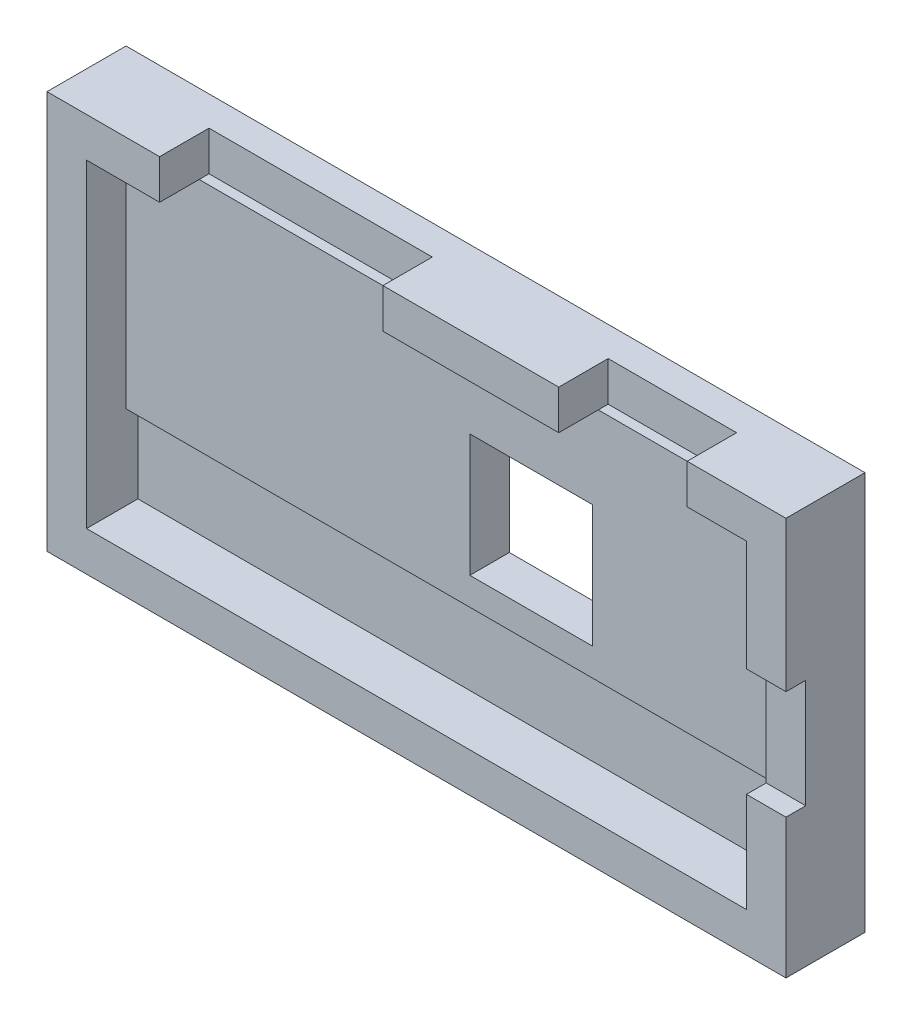
from build123d import *

# Parameters (mm, degrees)
SKETCH_1_W          = 74.8
SKETCH_1_H          = 40.3
EXTRUDE_1_DEPTH     = 4
SKETCH_2_W          = 74.8
SKETCH_2_H          = 40.3
SKETCH_2_W_2        = 66.8
SKETCH_2_H_2        = 32.3
EXTRUDE_1_2_DEPTH   = 4
SKETCH_3_R          = 2.125481821
SKETCH_3_R_2        = 2.41676927
SKETCH_3_R_3        = 2.07603791
SKETCH_3_R_4        = 2.373619113
EXTRUDE_2_DEPTH     = 1
SKETCH_4_W          = 4
SKETCH_4_H          = 11
CUT_EXTRUDE_1_DEPTH = 2
SKETCH_6_W          = 66.8
SKETCH_6_H          = 8.5
CUT_EXTRUDE_3_DEPTH = 1.2
SKETCH_7_W          = 13
SKETCH_7_H          = 4
SKETCH_7_W_2        = 22.6
CUT_EXTRUDE_4_DEPTH = 5
CUT_EXTRUDE_5_REACH = 7
SKETCH_9_W          = 12.4
SKETCH_9_H          = 12.4


with BuildPart() as part:
    # 草圖1 → Extrude 1 (new body)
    with BuildSketch(Plane.XY):
        with Locations((-0.94084879, -0.070758559)):
            Rectangle(SKETCH_1_W, SKETCH_1_H)
    extrude(amount=EXTRUDE_1_DEPTH)

    # 草圖2 → Extrude 1 2 (add)
    with BuildSketch(Plane.XY.offset(4)):
        with Locations((-0.94084879, -0.070758559)):
            Rectangle(SKETCH_2_W, SKETCH_2_H)
        with Locations((-0.94084879, -0.070758559)):
            Rectangle(SKETCH_2_W_2, SKETCH_2_H_2, mode=Mode.SUBTRACT)
    extrude(amount=EXTRUDE_1_2_DEPTH)

    # 草圖3 → 填料-伸長2 (add)
    with BuildSketch(Plane(origin=(0, 0, 0), x_dir=(-1, 0, 0), z_dir=(0, 0, -1))):
        with Locations((-28.45915121, 12.079241441)):
            Circle(SKETCH_3_R)
        with Locations((30.34084879, 12.079241441)):
            Circle(SKETCH_3_R_2)
        with Locations((-28.45915121, -12.220758559)):
            Circle(SKETCH_3_R_3)
        with Locations((30.34084879, -12.220758559)):
            Circle(SKETCH_3_R_4)
    extrude(amount=EXTRUDE_2_DEPTH)

    # 草圖4 → 除料-伸長1 (cut)
    with BuildSketch(Plane.XY.offset(8)):
        with Locations((34.45915121, -0.620758559)):
            Rectangle(SKETCH_4_W, SKETCH_4_H)
    extrude(amount=-CUT_EXTRUDE_1_DEPTH, mode=Mode.SUBTRACT)

    # 草圖6 → 除料-伸長3 (cut)
    with BuildSketch(Plane.XY.offset(4)):
        with Locations((-0.94084879, -11.970758559)):
            Rectangle(SKETCH_6_W, SKETCH_6_H)
    extrude(amount=-CUT_EXTRUDE_3_DEPTH, mode=Mode.SUBTRACT)

    # 草圖7 → 除料-伸長4 (cut)
    with BuildSketch(Plane.XY.offset(8)):
        with Locations((19.95915121, 18.079241441)):
            Rectangle(SKETCH_7_W, SKETCH_7_H)
        with Locations((-15.64084879, 18.079241441)):
            Rectangle(SKETCH_7_W_2, SKETCH_7_H)
    extrude(amount=-CUT_EXTRUDE_4_DEPTH, mode=Mode.SUBTRACT)

    # 草圖9 → 除料-伸長5 (cut, up to next)
    with BuildSketch(Plane.XY.offset(4), mode=Mode.PRIVATE) as cut_extrude_5_sk1:
        with Locations((6.65915121, 1.279241441)):
            Rectangle(SKETCH_9_W, SKETCH_9_H)
    cut_extrude_5_tool1 = extrude(cut_extrude_5_sk1.sketch, amount=-CUT_EXTRUDE_5_REACH, mode=Mode.PRIVATE) & part.part
    add(cut_extrude_5_tool1.solids().sort_by_distance((6.659151, 1.279241, 4))[0], mode=Mode.SUBTRACT)


solid = part.part
